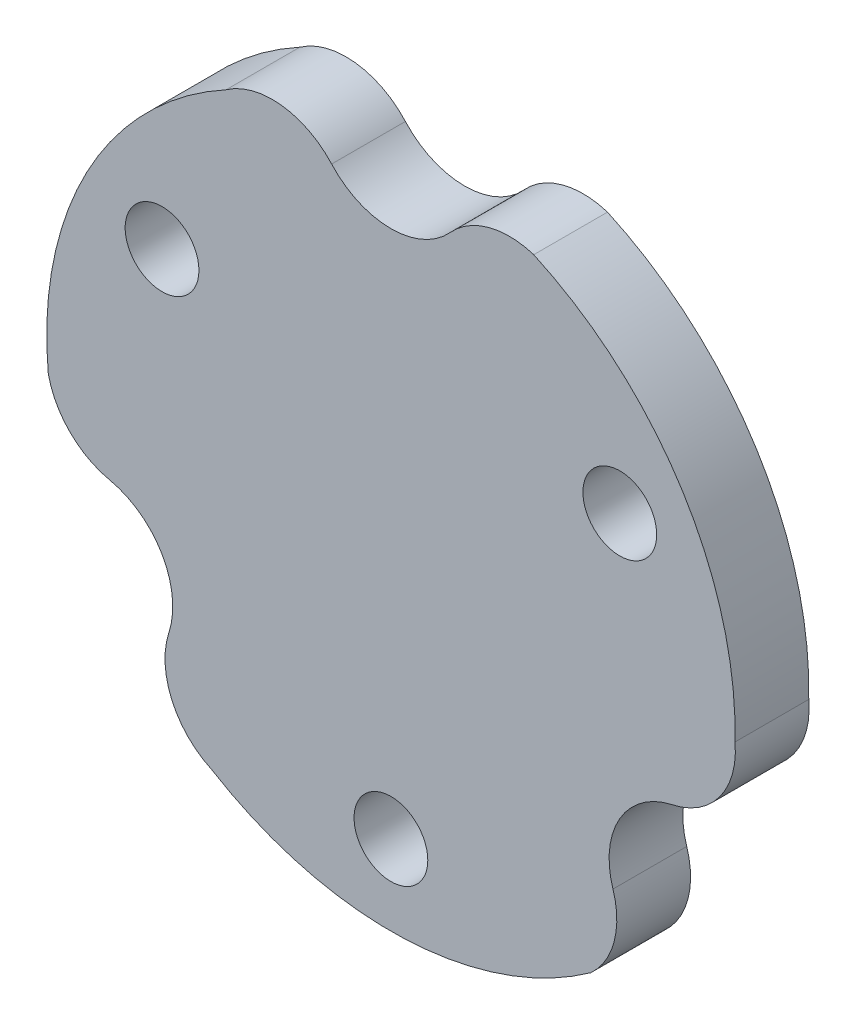
from build123d import *

# Parameters (mm, degrees)
ESQUISSE1_R        = 1.5
BOSS_EXTRU_2_DEPTH = 3


with BuildPart() as part:
    # Esquisse1 → Boss.-Extru.2 (new body)
    with BuildSketch(Plane.XY):
        with BuildLine():
            ThreePointArc((-2.411034891, 11.820685714), (0, 10.75), (2.411034891, 11.820685714))
            ThreePointArc((2.411034891, 11.820685714), (3.975330286, 12.779130538), (5.80943088, 12.737759334))
            ThreePointArc((5.80943088, 12.737759334), (11.865562564, 7.430237213), (13.995977593, -0.335575935))
            ThreePointArc((13.995977593, -0.335575935), (13.382779595, -2.564868949), (11.442531564, -3.822325392))
            ThreePointArc((11.442531564, -3.822325392), (9.309773091, -5.375), (9.031496673, -7.998360322))
            ThreePointArc((9.031496673, -7.998360322), (9.079386541, -9.832302285), (8.126507731, -11.399994391))
            ThreePointArc((8.126507731, -11.399994391), (0.5019929, -13.990997217), (-7.288606081, -11.953084179))
            ThreePointArc((-7.288606081, -11.953084179), (-8.912631465, -10.307392628), (-9.031496673, -7.998360322))
            ThreePointArc((-9.031496673, -7.998360322), (-9.309773091, -5.375), (-11.442531564, -3.822325392))
            ThreePointArc((-11.442531564, -3.822325392), (-13.054716827, -2.946828253), (-13.935938611, -1.337764944))
            ThreePointArc((-13.935938611, -1.337764944), (-12.367555464, 6.560760004), (-6.707371512, 12.288660114))
            ThreePointArc((-6.707371512, 12.288660114), (-4.47014813, 12.872261577), (-2.411034891, 11.820685714))
        make_face()
        with Locations((9.309773091, 5.375)):
            Circle(ESQUISSE1_R, mode=Mode.SUBTRACT)
        with Locations((0, -10.75)):
            Circle(ESQUISSE1_R, mode=Mode.SUBTRACT)
        with Locations((-9.309773091, 5.375)):
            Circle(ESQUISSE1_R, mode=Mode.SUBTRACT)
    extrude(amount=BOSS_EXTRU_2_DEPTH)


solid = part.part
